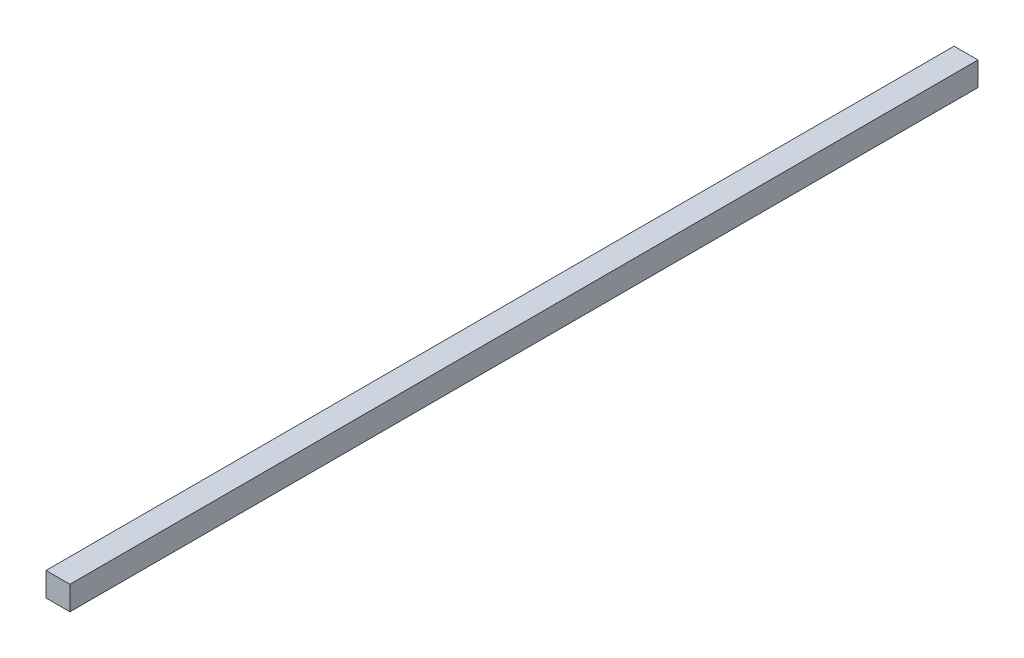
from build123d import *

# Parameters (mm, degrees)
SKETCH1_W      = 20
SKETCH1_H      = 760
EXTRUDE1_DEPTH = 20


with BuildPart() as part:
    # Sketch1 → Extrude1 (new body)
    with BuildSketch(Plane(origin=(0, 0, 0), x_dir=(1, 0, 0), z_dir=(0, 1, 0))):
        Rectangle(SKETCH1_W, SKETCH1_H)
    extrude(amount=EXTRUDE1_DEPTH)


solid = part.part
